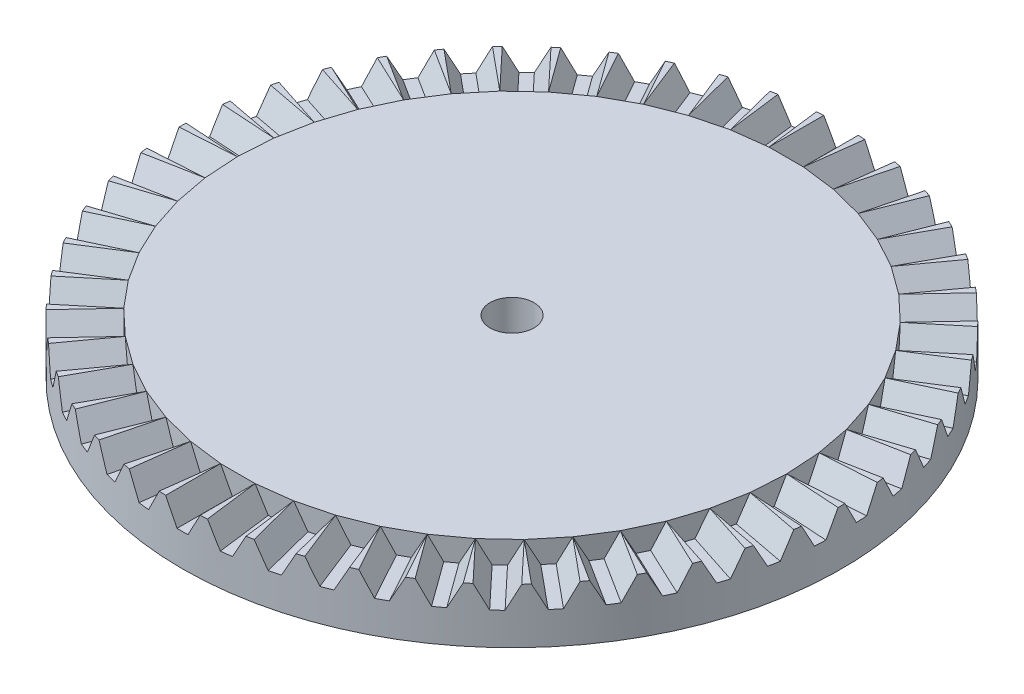
from build123d import *

# Parameters (mm, degrees)
SKETCH3_R                = 30
BOSS_EXTRUDE3_DEPTH      = 5
CUT_EXTRUDE1_REACH       = 44.72
SKETCH6_R                = 2
CUT_EXTRUDE2_DEPTH       = 3
BOSS_EXTRUDE4_REACH      = 64.813
BOSS_EXTRUDE4_END_RADIUS = 30
CIRPATTERN1_COUNT        = 50


with BuildPart() as part:
    # Sketch3 → Boss-Extrude3 (new body)
    with BuildSketch(Plane(origin=(0, 0, 0), x_dir=(1, 0, 0), z_dir=(0, 1, 0))):
        with Locations(Location((0, 0, 0), (0, 0, 270))):
            Circle(SKETCH3_R)
    extrude(amount=BOSS_EXTRUDE3_DEPTH)

    # Sketch6 → Cut-Extrude1 (cut, up to next)
    with BuildSketch(Plane(origin=(0, 5, 0), x_dir=(1, 0, 0), z_dir=(0, 1, 0)), mode=Mode.PRIVATE) as cut_extrude1_sk1:
        with Locations(Location((0, 0, 0), (0, 0, 270))):
            Circle(SKETCH6_R)
    cut_extrude1_tool1 = extrude(cut_extrude1_sk1.sketch, amount=-CUT_EXTRUDE1_REACH, mode=Mode.PRIVATE) & part.part
    add(cut_extrude1_tool1.solids().sort_by_distance((0, 5, 0))[0], mode=Mode.SUBTRACT)

    # Sketch5 → Cut-Extrude2 (cut)
    with BuildSketch(Plane(origin=(0, 5, 0), x_dir=(1, 0, 0), z_dir=(0, 1, 0))):
        with BuildLine():
            Line((-1.570078687, 29.958886043), (-1.570078687, 24.958886043))
            Line((-1.570078687, 24.958886043), (1.570078687, 24.958886043))
            Line((1.570078687, 24.958886043), (1.570078687, 29.958886043))
            ThreePointArc((1.570078687, 29.958886043), (0, 30), (-1.570078687, 29.958886043))
        make_face()
    cut_extrude2 = extrude(amount=-CUT_EXTRUDE2_DEPTH, mode=Mode.SUBTRACT)

    # Boss-Extrude4: up to this cylinder (the profile starts inside it)
    boss_extrude4_end = Plane(origin=(0, 2.043429, 0), z_dir=(0, -1, 0)) * Cylinder(BOSS_EXTRUDE4_END_RADIUS, 190.626, mode=Mode.PRIVATE)
    # Sketch7 → Boss-Extrude4 (add, up to the surface)
    with BuildSketch(Plane(origin=(0, 0, -24.958886043), x_dir=(-1, 0, 0), z_dir=(0, 0, -1)), mode=Mode.PRIVATE) as boss_extrude4_sk1:
        Polygon((-1.570078687, 2), (1.570078687, 2), (1.570078687, 5), (0.497191584, 2.95), (-0.497191584, 2.95), (-1.570078687, 5), align=None)
    boss_extrude4_tool1 = extrude(boss_extrude4_sk1.sketch, amount=BOSS_EXTRUDE4_REACH, mode=Mode.PRIVATE) & boss_extrude4_end
    boss_extrude4 = boss_extrude4_tool1.solids().sort_by_distance((0, 2.043429, -24.958886))[0]
    add(boss_extrude4)

    # CirPattern1: Cut-Extrude2, Boss-Extrude4 ×50 about axis
    cirpattern1_axis = Axis((0, 0, 0), (0, 1, 0))
    add([cut_extrude2.rotate(cirpattern1_axis, i * 360 / CIRPATTERN1_COUNT) for i in range(1, CIRPATTERN1_COUNT)], mode=Mode.SUBTRACT)
    add([boss_extrude4.rotate(cirpattern1_axis, i * 360 / CIRPATTERN1_COUNT) for i in range(1, CIRPATTERN1_COUNT)])


solid = part.part
